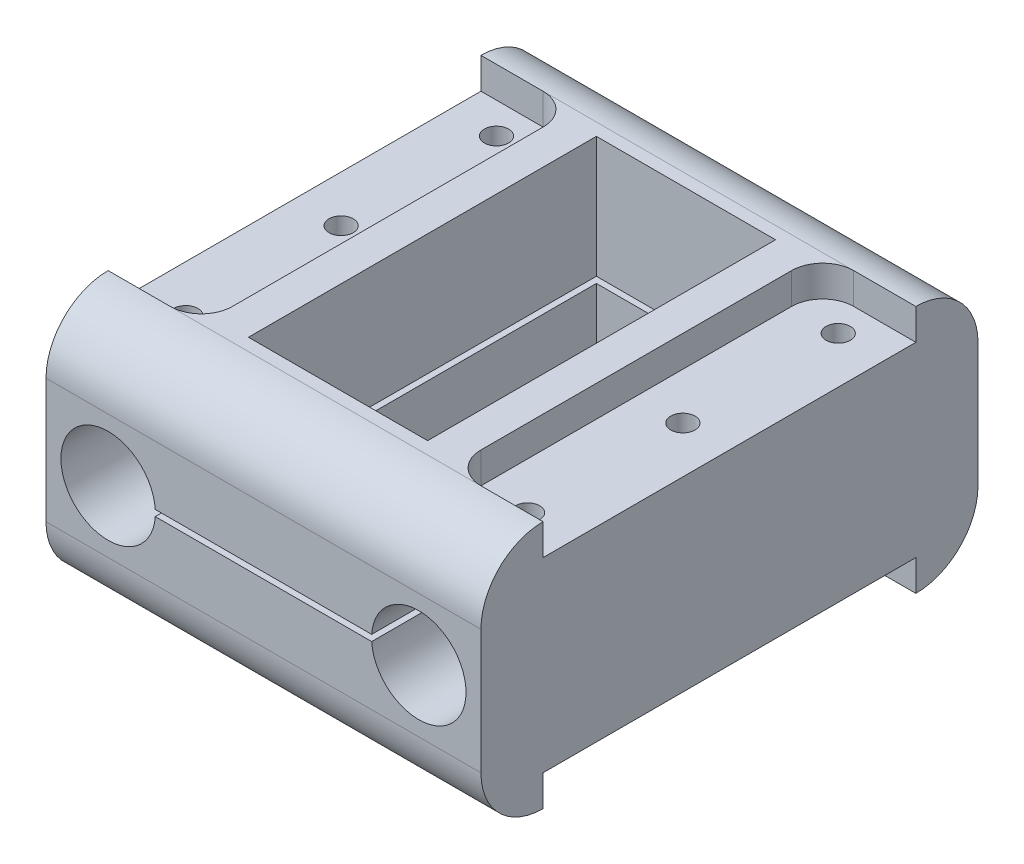
from build123d import *

# Parameters (mm, degrees)
SKETCH1_W                    = 70
SKETCH1_H                    = 40
SKETCH1_R                    = 7.6
BOSS_EXTRUDE1_DEPTH          = 80
FILLET1_R                    = 10
CUT_EXTRUDE_THIN1_DEPTH      = 1
CUT_EXTRUDE_THIN1_DEPTH_BACK = 95
SKETCH24_W                   = 28.832930408
SKETCH24_H                   = 56
CUT_EXTRUDE15_DEPTH          = 39
CUT_EXTRUDE15_DEPTH_BACK     = 40
CUT_EXTRUDE17_DEPTH          = 5
SKETCH28_R                   = 1.95
CUT_EXTRUDE18_DEPTH          = 20
MIRROR2_COPY_1_DEPTH         = 5
MIRROR2_COPY_2_SKETCH_R      = 1.95
MIRROR2_COPY_2_DEPTH         = 20


with BuildPart() as part:
    # Sketch1 → Boss-Extrude1 (new body)
    with BuildSketch(Plane.XY):
        with Locations((25, 0)):
            Rectangle(SKETCH1_W, SKETCH1_H)
        Circle(SKETCH1_R, mode=Mode.SUBTRACT)
        with Locations((50, 0)):
            Circle(SKETCH1_R, mode=Mode.SUBTRACT)
    extrude(amount=BOSS_EXTRUDE1_DEPTH)

    # Fillet1
    fillet1_edges = [part.edges().sort_by_distance(p)[0] for p in [
        (25, -20, 80),
        (25, -20, 0),
        (25, 20, 0),
        (25, 20, 80),
    ]]
    fillet(fillet1_edges, radius=FILLET1_R)

    # Sketch12 → Cut-Extrude-Thin1 (cut, two sides)
    with BuildSketch(Plane.XY.offset(80)) as cut_extrude_thin1_sk:
        Polygon((3.119310539, -0.5), (7.6, -0.5), (42.4, -0.5), (46.98201893, -0.5), (46.98201893, 0.5), (42.4, 0.5), (7.6, 0.5), (3.119310539, 0.5), align=None)
    extrude(amount=CUT_EXTRUDE_THIN1_DEPTH, mode=Mode.SUBTRACT)
    extrude(cut_extrude_thin1_sk.sketch, amount=-CUT_EXTRUDE_THIN1_DEPTH_BACK, mode=Mode.SUBTRACT)

    # Sketch24 → Cut-Extrude15 (cut, two sides)
    with BuildSketch(Plane.XZ.offset(-0.5)) as cut_extrude15_sk:
        with Locations((25, 40)):
            Rectangle(SKETCH24_W, SKETCH24_H)
    extrude(amount=CUT_EXTRUDE15_DEPTH, mode=Mode.SUBTRACT)
    extrude(cut_extrude15_sk.sketch, amount=-CUT_EXTRUDE15_DEPTH_BACK, mode=Mode.SUBTRACT)

    # Sketch27 → Cut-Extrude17 (cut)
    with BuildSketch(Plane(origin=(0, 20, 0), x_dir=(1, 0, 0), z_dir=(0, 1, 0))):
        with BuildLine():
            Line((-10, -10), (0, -10))
            ThreePointArc((0, -10), (3.535533906, -11.464466094), (5, -15))
            Line((5, -15), (5, -65))
            ThreePointArc((5, -65), (3.535533906, -68.535533906), (0, -70))
            Line((0, -70), (-10, -70))
            Line((-10, -70), (-10, -10))
        make_face()
    cut_extrude17 = extrude(amount=-CUT_EXTRUDE17_DEPTH, mode=Mode.SUBTRACT)

    # Sketch28 → Cut-Extrude18 (cut)
    with BuildSketch(Plane(origin=(0, 15, 0), x_dir=(1, 0, 0), z_dir=(0, 1, 0))):
        with Locations((-2.5, -15)):
            Circle(SKETCH28_R)
        with Locations((-2.5, -40)):
            Circle(SKETCH28_R)
        with Locations((-2.5, -65)):
            Circle(SKETCH28_R)
    cut_extrude18 = extrude(amount=-CUT_EXTRUDE18_DEPTH, mode=Mode.SUBTRACT)

    # Mirror1: Cut-Extrude17, Cut-Extrude18 across plane
    add(cut_extrude17.mirror(Plane.ZY.offset(-25)), mode=Mode.SUBTRACT)
    add(cut_extrude18.mirror(Plane.ZY.offset(-25)), mode=Mode.SUBTRACT)

    # Mirror2: Cut-Extrude17, Cut-Extrude18 across plane
    add(cut_extrude17.mirror(Plane.ZX), mode=Mode.SUBTRACT)
    add(cut_extrude18.mirror(Plane.ZX), mode=Mode.SUBTRACT)

    # Mirror2 copy 1 sketch → Mirror2 copy 1 (cut)
    with BuildSketch(Plane(origin=(50, -20, 0), x_dir=(-1, 0, 0), z_dir=(0, -1, 0))):
        with BuildLine():
            Line((-10, -10), (0, -10))
            ThreePointArc((0, -10), (3.535533906, -11.464466094), (5, -15))
            Line((5, -15), (5, -65))
            ThreePointArc((5, -65), (3.535533906, -68.535533906), (0, -70))
            Line((0, -70), (-10, -70))
            Line((-10, -70), (-10, -10))
        make_face()
    extrude(amount=-MIRROR2_COPY_1_DEPTH, mode=Mode.SUBTRACT)

    # Mirror2 copy 2 sketch → Mirror2 copy 2 (cut)
    with BuildSketch(Plane(origin=(50, -15, 0), x_dir=(-1, 0, 0), z_dir=(0, -1, 0))):
        with Locations((-2.5, -15)):
            Circle(MIRROR2_COPY_2_SKETCH_R)
        with Locations((-2.5, -40)):
            Circle(MIRROR2_COPY_2_SKETCH_R)
        with Locations((-2.5, -65)):
            Circle(MIRROR2_COPY_2_SKETCH_R)
    extrude(amount=-MIRROR2_COPY_2_DEPTH, mode=Mode.SUBTRACT)


solid = part.part
